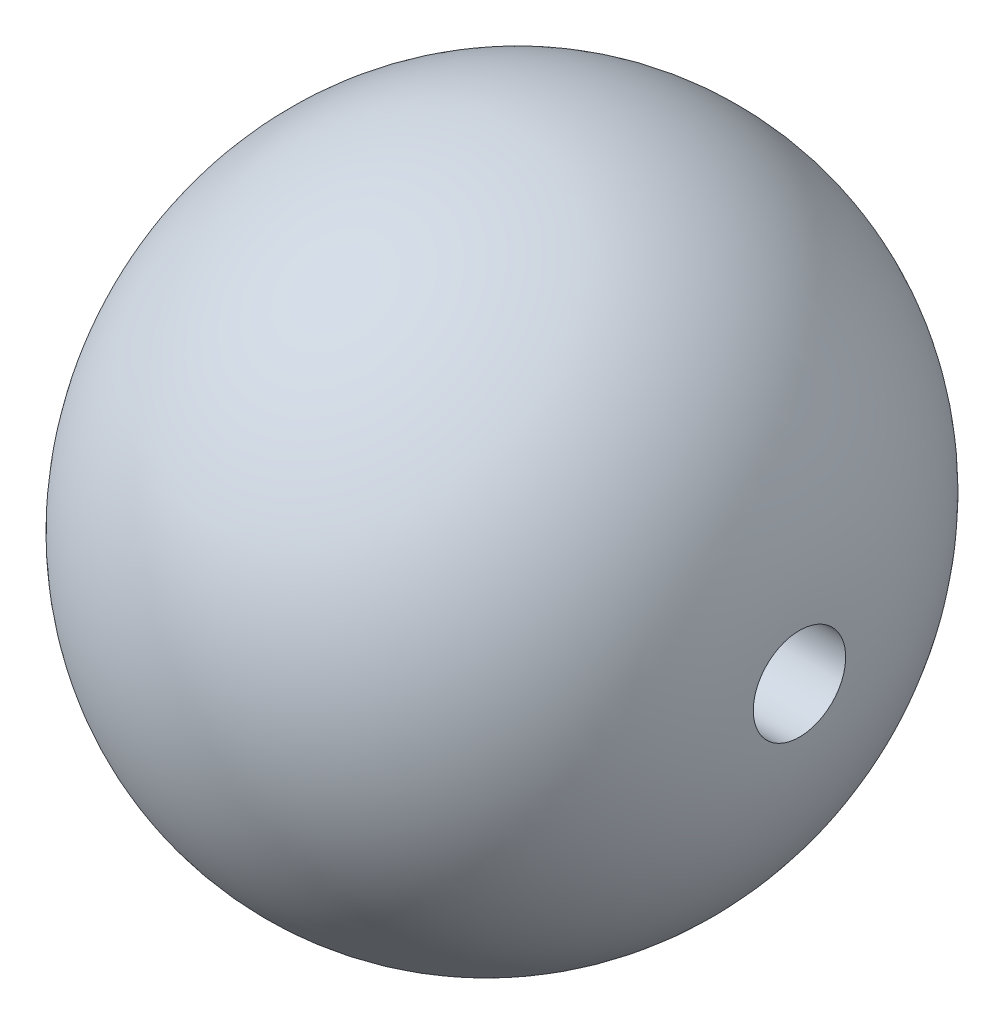
from build123d import *

# Parameters (mm, degrees)
SKETCH2_R               = 2.5
CUT_EXTRUDE1_DEPTH      = 27
CUT_EXTRUDE1_DEPTH_BACK = 26


with BuildPart() as part:
    # Sketch1 → Revolve1 (revolve)
    with BuildSketch(Plane(origin=(0, 0, 0), x_dir=(1, 0, 0), z_dir=(0, 1, 0))):
        with BuildLine():
            Line((0, 0), (16, 0))
            ThreePointArc((16, 0), (12.041594579, 12.592528514), (0, 18))
            Line((0, 18), (0, 0))
        make_face()
    revolve1 = revolve(axis=Axis((0, 0, 0), (1, 0, 0)))

    # Mirror2: Revolve1 across plane
    add(revolve1.mirror(Plane(origin=(0, 0, 0), x_dir=(0, 0, 1), z_dir=(1, 0, 0))))

    # Sketch2 → Cut-Extrude1 (cut, two sides)
    with BuildSketch(Plane(origin=(0, 0, 0), x_dir=(0, 0, -1), z_dir=(1, 0, 0))) as cut_extrude1_sk:
        Circle(SKETCH2_R)
    extrude(amount=CUT_EXTRUDE1_DEPTH, mode=Mode.SUBTRACT)
    extrude(cut_extrude1_sk.sketch, amount=-CUT_EXTRUDE1_DEPTH_BACK, mode=Mode.SUBTRACT)


solid = part.part
